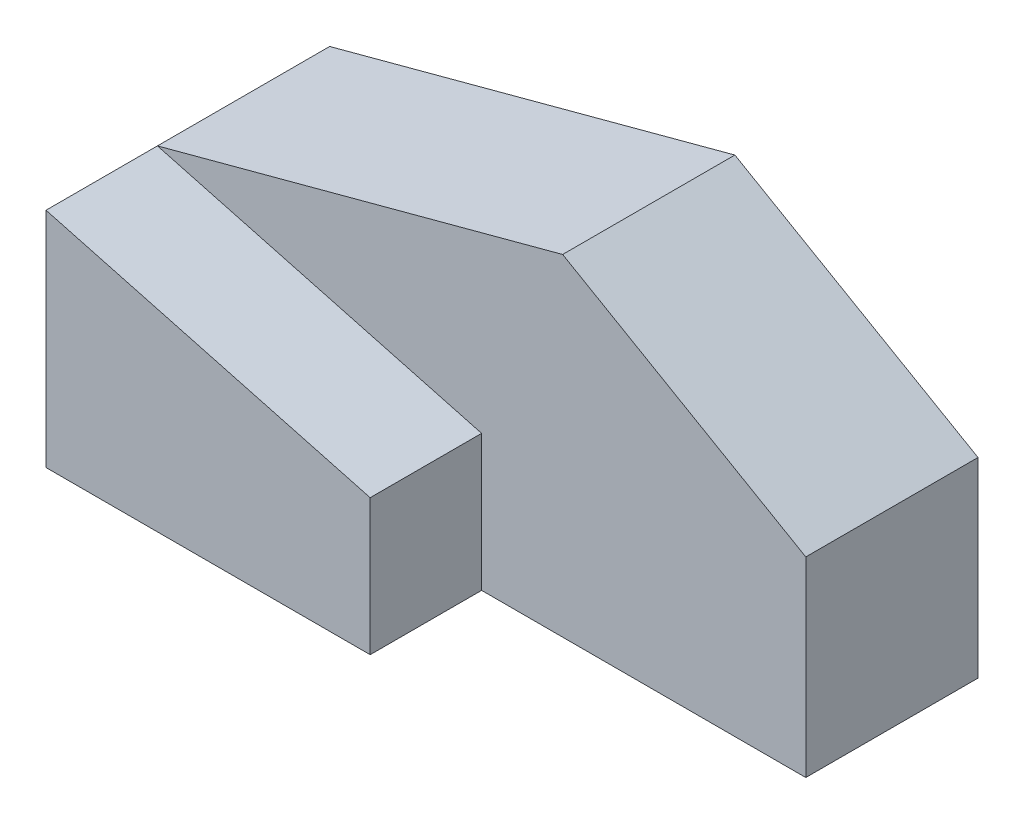
from build123d import *

# Parameters (mm, degrees)
BOSS_EXTRUDE1_DEPTH = 13.49375
BOSS_EXTRUDE2_DEPTH = 17.4625


with BuildPart() as part:
    # Sketch1 → Boss-Extrude1 (new body, symmetric)
    with BuildSketch(Plane.XY):
        Polygon((50.8, 0), (-50.8, 0), (-50.8, 34.925), (12.7, 51.939773719), (50.8, 29.942728463), align=None)
    extrude(amount=BOSS_EXTRUDE1_DEPTH, both=True)

    # Sketch2 → Boss-Extrude2 (add)
    with BuildSketch(Plane.XY.offset(13.49375)):
        Polygon((-50.8, 0), (-50.8, 34.925), (0, 21.313181024), (0, 0), align=None)
    extrude(amount=BOSS_EXTRUDE2_DEPTH)


solid = part.part
